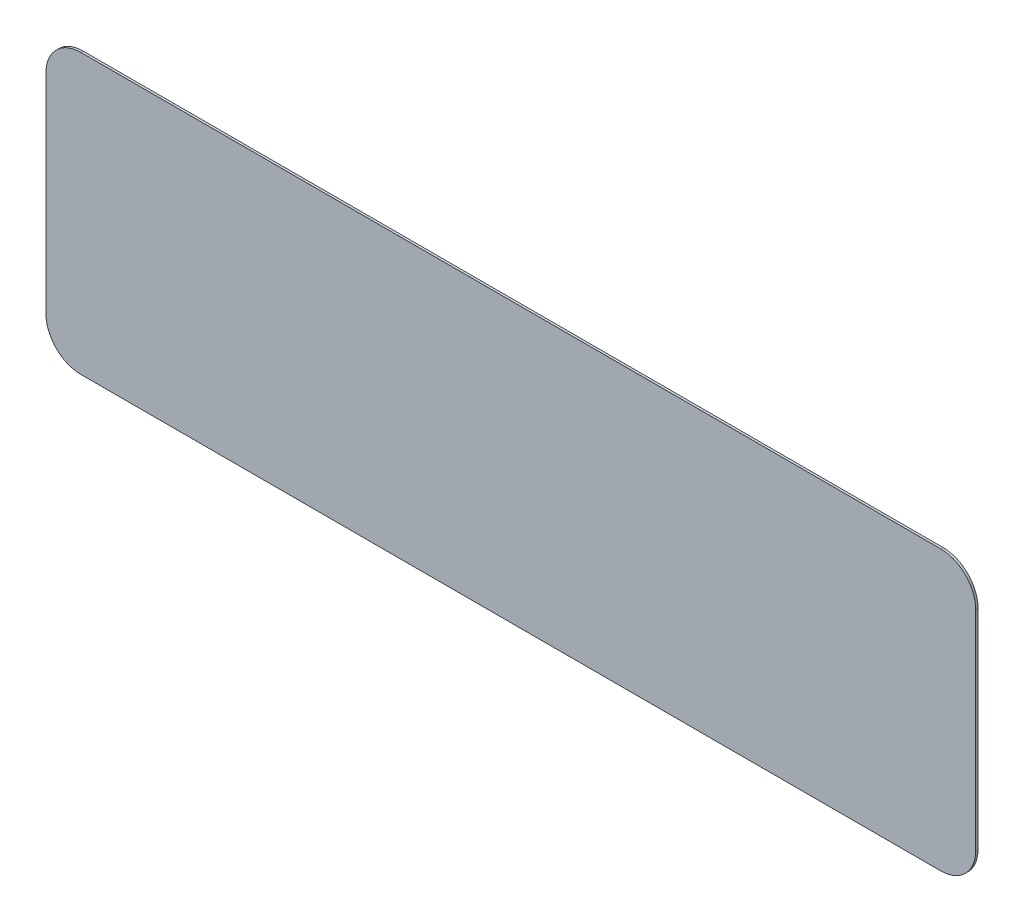
from build123d import *

# Parameters (mm, degrees)
BOSS_EXTRUDE1_DEPTH = 0.1


with BuildPart() as part:
    # Sketch1 → Boss-Extrude1 (new body)
    with BuildSketch(Plane.XY):
        with BuildLine():
            Line((-18.5, 0), (18.5, 0))
            ThreePointArc((18.5, 0), (19.560660172, 0.439339828), (20, 1.5))
            Line((20, 1.5), (20, 10.5))
            ThreePointArc((20, 10.5), (19.560660172, 11.560660172), (18.5, 12))
            Line((18.5, 12), (-18.5, 12))
            ThreePointArc((-18.5, 12), (-19.560660172, 11.560660172), (-20, 10.5))
            Line((-20, 10.5), (-20, 1.5))
            ThreePointArc((-20, 1.5), (-19.560660172, 0.439339828), (-18.5, 0))
        make_face()
    extrude(amount=BOSS_EXTRUDE1_DEPTH)


solid = part.part
